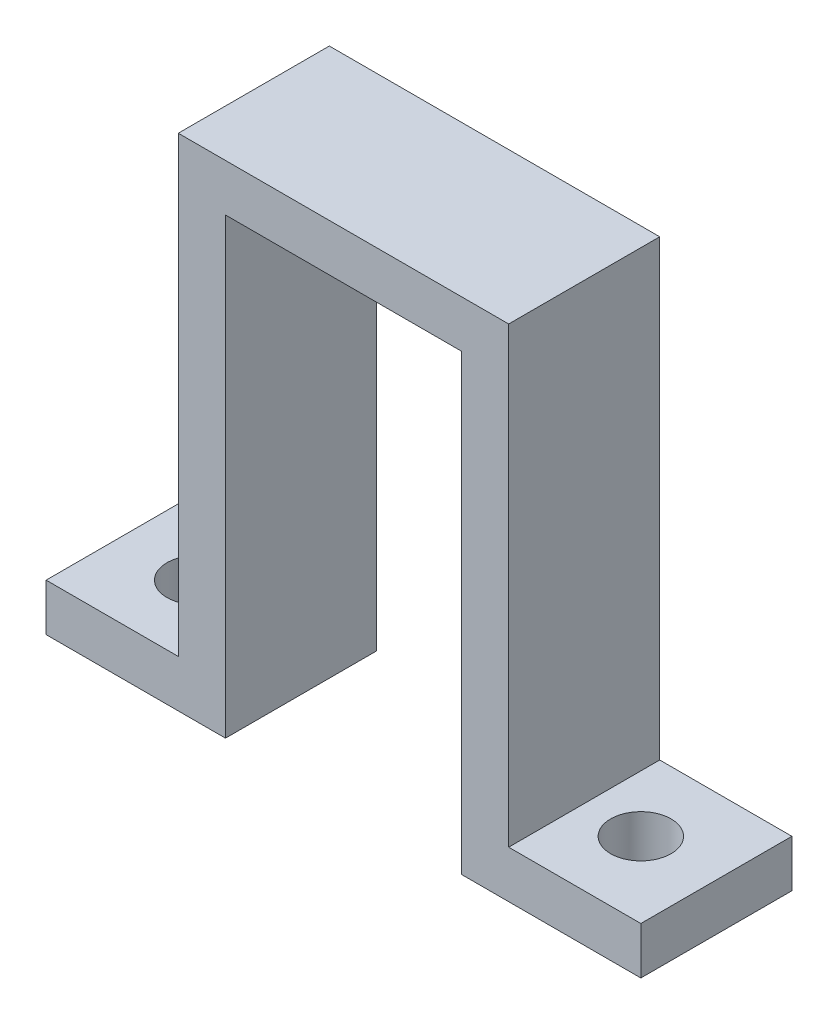
from build123d import *

# Parameters (mm, degrees)
BOSS_EXTRUDE1_DEPTH = 8
SKETCH2_R           = 1.6
CUT_EXTRUDE1_DEPTH  = 10


with BuildPart() as part:
    # Sketch1 → Boss-Extrude1 (new body)
    with BuildSketch(Plane.XY):
        Polygon((-6.153153153, -0.652491564), (-15.653153153, -0.652491564), (-15.653153153, 1.847508436), (-8.653153153, 1.847508436), (-8.653153153, 25.847508436), (8.846846847, 25.847508436), (8.846846847, 1.847508436), (15.846846847, 1.847508436), (15.846846847, -0.652491564), (6.346846847, -0.652491564), (6.346846847, 23.347508436), (-6.153153153, 23.347508436), align=None)
    extrude(amount=BOSS_EXTRUDE1_DEPTH)

    # Sketch2 → Cut-Extrude1 (cut)
    with BuildSketch(Plane(origin=(0, 1.847508436, 0), x_dir=(1, 0, 0), z_dir=(0, 1, 0))):
        with Locations((-11.653153153, -4)):
            Circle(SKETCH2_R)
        with Locations((11.846846847, -4)):
            Circle(SKETCH2_R)
    extrude(amount=-CUT_EXTRUDE1_DEPTH, mode=Mode.SUBTRACT)


solid = part.part
